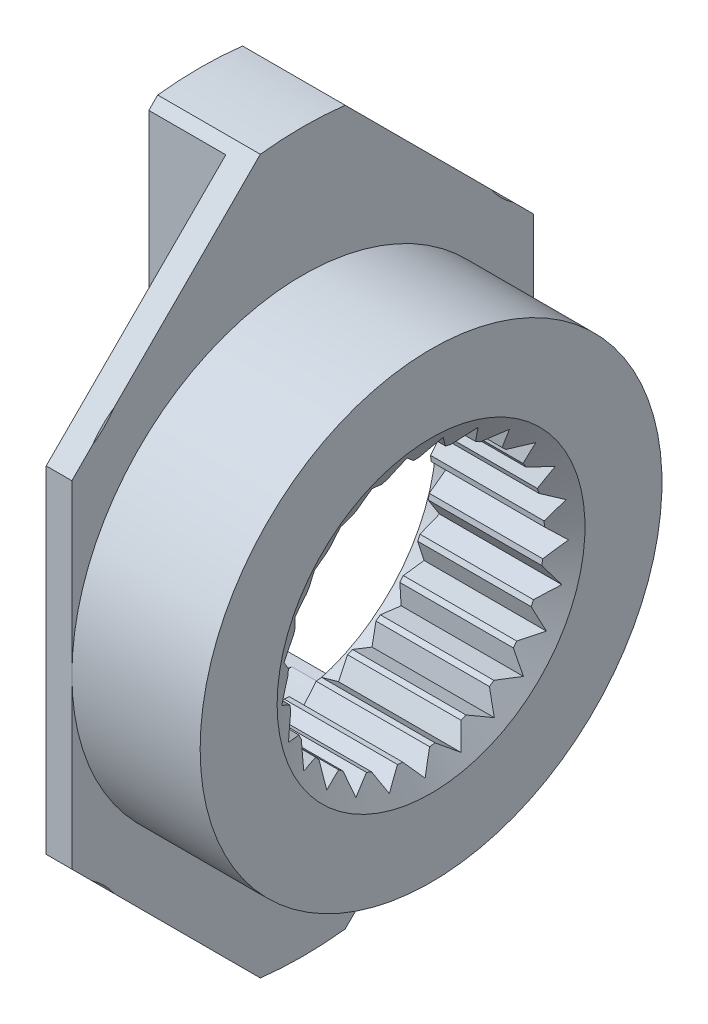
from build123d import *

# Parameters (mm, degrees)
CHAMFER_1_SIZE           = 0.5
CHAMFER_1_SIZE2          = 0.288675135
CUT_EXTRUDE_1_DEPTH      = 2.5
M3X0_51_AT_2_COUNT       = 2
M3X0_51_AT_2_PITCH       = 10
M3X0_51_AT_3_COUNT       = 2
M3X0_51_AT_3_PITCH       = 14.142135624
M3X0_51_AT_4_COUNT       = 2
M3X0_51_AT_4_PITCH       = 10
SKETCH_7_W               = 2
SKETCH_7_H               = 3
SKETCH_8_OUTSIDE_W       = 20.06
SKETCH_8_OUTSIDE_H       = 20.06
CUT_EXTRUDE_2_DEPTH      = 2.2
SKETCH_9_W               = 1.5
SKETCH_9_H               = 6
CUT_EXTRUDE_3_DEPTH      = 10
CUT_EXTRUDE_4_DEPTH      = 8
CUT_EXTRUDE_4_DEPTH_BACK = 8


with BuildPart() as part:
    # Эскиз1 → Повернуть1 (revolve)
    with BuildSketch(Plane.XY):
        Polygon((0, 1.5), (0, 10), (2, 10), (2, 4.5), (4.5, 4.5), (4.5, 2.5), (2, 2.5), (2, 3.1), (1, 3.1), (1, 1.5), align=None)
    revolve(axis=Axis((0, 0, 0), (1, 0, 0)))

    # Фаска1
    chamfer_1_edges = [part.edges().sort_by_distance(p)[0] for p in [
        (4.5, -2.5, 0),
    ]]
    chamfer_1_side = [part.faces().sort_by_distance(p)[0] for p in [
        (4.5, -4.372720779, 0),
    ]]
    chamfer(chamfer_1_edges, length=CHAMFER_1_SIZE, length2=CHAMFER_1_SIZE2, reference=chamfer_1_side[0])

    # Эскиз3 → Вырез-Вытянуть1 (cut)
    with BuildSketch(Plane(origin=(4.5, 0, 0), x_dir=(0, 0, -1), z_dir=(1, 0, 0))):
        Polygon((0, 2.45), (0.350933054, 2.777921164), (0.609290224, 2.373028745), (1.030748748, 2.60337416), (1.180296502, 2.146951366), (1.645798706, 2.265247584), (1.67714041, 1.785973137), (2.15743708, 1.784787171), (2.068603417, 1.312775648), (2.533515747, 1.192182016), (2.330088465, 0.757091636), (2.750404302, 0.524667681), (2.445165485, 0.153836773), (2.79447484, -0.175813455), (2.406603764, -0.459084221), (2.662958246, -0.865247584), (2.216826279, -1.043159264), (2.364118191, -1.500315026), (1.887757445, -1.561688775), (1.916731897, -2.041112157), (1.440073868, -1.982091636), (1.348910287, -2.453658704), (0.901905154, -2.27795239), (0.696331684, -2.712032851), (0.307066422, -2.430681018), (0, -2.8), (-0.307066422, -2.430681018), (-0.696331684, -2.712032851), (-0.901905154, -2.27795239), (-1.348910287, -2.453658704), (-1.440073868, -1.982091636), (-1.916731897, -2.041112157), (-1.887757445, -1.561688775), (-2.364118191, -1.500315026), (-2.216826279, -1.043159264), (-2.662958246, -0.865247584), (-2.406603764, -0.459084221), (-2.79447484, -0.175813455), (-2.445165485, 0.153836773), (-2.750404302, 0.524667681), (-2.330088465, 0.757091636), (-2.533515747, 1.192182016), (-2.068603417, 1.312775648), (-2.15743708, 1.784787171), (-1.67714041, 1.785973137), (-1.645798706, 2.265247584), (-1.180296502, 2.146951366), (-1.030748748, 2.60337416), (-0.609290224, 2.373028745), (-0.350933054, 2.777921164), align=None)
    extrude(amount=-CUT_EXTRUDE_1_DEPTH, mode=Mode.SUBTRACT)

    # Эскиз6 → Отверстие обработанное метчиком M3x0.51 (revolve, cut)
    with BuildSketch(Plane(origin=(0, 5, -5), x_dir=(0, 0, 1), z_dir=(0, 1, 0))):
        Polygon((0, 0), (0, 2), (1.6, 2), (1.25, 1.754927362), (1.25, 0.245072638), (1.6, 0), align=None)
    m3x0_51 = revolve(axis=Axis((-6.35, 5, -5), (1, 0, 0)), mode=Mode.SUBTRACT)

    # Отверстие обработанное метчиком M3x0.51 at 2: Отверстие обработанное метчиком M3x0.51 ×2
    with Locations(*[(0, 0, i * M3X0_51_AT_2_PITCH) for i in range(1, M3X0_51_AT_2_COUNT)]):
        add(m3x0_51, mode=Mode.SUBTRACT)

    # Отверстие обработанное метчиком M3x0.51 at 3: Отверстие обработанное метчиком M3x0.51 ×2
    with Locations(*[Vector(0, -0.707106781, 0.707106781) * (i * M3X0_51_AT_3_PITCH) for i in range(1, M3X0_51_AT_3_COUNT)]):
        add(m3x0_51, mode=Mode.SUBTRACT)

    # Отверстие обработанное метчиком M3x0.51 at 4: Отверстие обработанное метчиком M3x0.51 ×2
    with Locations(*[(0, -i * M3X0_51_AT_4_PITCH, 0) for i in range(1, M3X0_51_AT_4_COUNT)]):
        add(m3x0_51, mode=Mode.SUBTRACT)

    # Эскиз7 → Вырез-Повернуть1 (revolve, cut)
    with BuildSketch(Plane.XY):
        with Locations((1, 8.5)):
            Rectangle(SKETCH_7_W, SKETCH_7_H)
    revolve(axis=Axis((0, 0, 0), (1, 0, 0)), mode=Mode.SUBTRACT)

    # Эскиз8 outside → Вырез-Вытянуть2 (cut)
    with BuildSketch(Plane.ZY):
        Rectangle(SKETCH_8_OUTSIDE_W, SKETCH_8_OUTSIDE_H)
        Polygon((-0.827225118, 6.950949475), (-4.5, 3.278174593), (-4.5, -3.278174593), (-0.827225118, -6.950949475), (-0.827225118, -8.301176924), (0.827225118, -8.301176924), (0.827225118, -6.950949475), (4.5, -3.278174593), (4.5, 3.278174593), (0.827225118, 6.950949475), (0.827225118, 9.049308712), (-0.827225118, 9.049308712), align=None, mode=Mode.SUBTRACT)
    extrude(amount=-CUT_EXTRUDE_2_DEPTH, mode=Mode.SUBTRACT)

    # Эскиз9 → Вырез-Вытянуть3 (cut, through all)
    with BuildSketch(Plane(origin=(0, 0, -4.5), x_dir=(-1, 0, 0), z_dir=(0, 0, -1))):
        with Locations((-0.75, 0)):
            Rectangle(SKETCH_9_W, SKETCH_9_H)
    extrude(amount=-CUT_EXTRUDE_3_DEPTH, mode=Mode.SUBTRACT)

    # Эскиз10 → Вырез-Вытянуть4 (cut, two sides)
    with BuildSketch(Plane(origin=(0, 0, 0), x_dir=(1, 0, 0), z_dir=(0, 1, 0))) as cut_extrude_4_sk:
        Polygon((0, -1), (0, 1), (1.5, 1), (1.5, 5.512863142), (-0.606676523, 5.512863142), (-0.606676523, -5.078399816), (1.5, -5.078399816), (1.5, -1), align=None)
    extrude(amount=CUT_EXTRUDE_4_DEPTH, mode=Mode.SUBTRACT)
    extrude(cut_extrude_4_sk.sketch, amount=-CUT_EXTRUDE_4_DEPTH_BACK, mode=Mode.SUBTRACT)


solid = part.part
